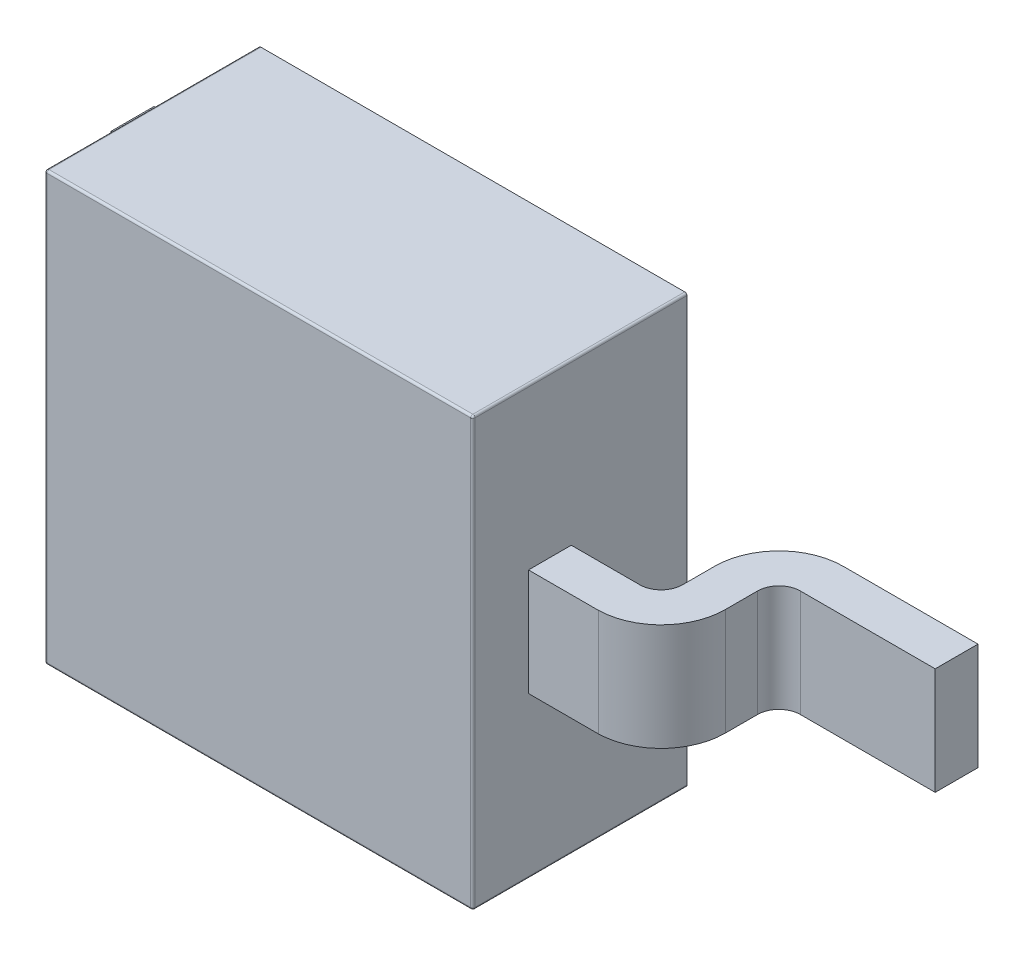
from build123d import *

# Parameters (mm, degrees)
SKETCH1_W      = 2
SKETCH1_H      = 2
EXTRUDE1_DEPTH = 1
SKETCH2_W      = 2
SKETCH2_H      = 1
EXTRUDE2_DEPTH = 0.2
SKETCH3_W      = 1.35
SKETCH3_H      = 0.5
EXTRUDE3_DEPTH = 0.75
EXTRUDE4_DEPTH = 2.25
FILLET1_R      = 0.01


with BuildPart() as part:
    # Sketch1 → Extrude1 (new body)
    with BuildSketch(Plane.XY.offset(0.01)):
        Rectangle(SKETCH1_W, SKETCH1_H)
    extrude(amount=EXTRUDE1_DEPTH)

    # Sketch2 → Extrude2 (add)
    with BuildSketch(Plane.XY):
        with Locations((-0.5, 0)):
            Rectangle(SKETCH2_W, SKETCH2_H)
    extrude(amount=EXTRUDE2_DEPTH)

    # Sketch3 → Extrude3 (add)
    with BuildSketch(Plane.XY):
        with Locations((1.675, 0)):
            Rectangle(SKETCH3_W, SKETCH3_H)
    extrude(amount=EXTRUDE3_DEPTH)

    # Sketch4 → Extrude4 (cut, through all)
    with BuildSketch(Plane.XZ.offset(0.25)):
        with BuildLine():
            Line((2.35, 0.2), (2.35, 0.75))
            Line((2.35, 0.75), (1.32, 0.750107803))
            ThreePointArc((1.32, 0.750107803), (1.532132034, 0.662239837), (1.62, 0.450107803))
            Line((1.62, 0.450107803), (1.62, 0.3))
            ThreePointArc((1.62, 0.3), (1.649289322, 0.229289322), (1.72, 0.2))
            Line((1.72, 0.2), (2.35, 0.2))
        make_face()
        with BuildLine():
            Line((1.32, 0.550107803), (1, 0.550107803))
            Line((1, 0.550107803), (1, 0))
            Line((1, 0), (1.72, 0))
            ThreePointArc((1.72, 0), (1.507867966, 0.087867966), (1.42, 0.3))
            Line((1.42, 0.3), (1.42, 0.450107803))
            ThreePointArc((1.42, 0.450107803), (1.390710678, 0.520818481), (1.32, 0.550107803))
        make_face()
    extrude(amount=-EXTRUDE4_DEPTH, mode=Mode.SUBTRACT)

    # Fillet1
    fillet1_edges = [part.edges().sort_by_distance(p)[0] for p in [
        (1, 0, 1.01),
        (0, 1, 1.01),
        (-1, 0, 1.01),
        (0, -1, 1.01),
        (-1, 1, 0.51),
        (1, 1, 0.51),
        (1, -1, 0.51),
        (-1, -1, 0.51),
    ]]
    fillet(fillet1_edges, radius=FILLET1_R)


solid = part.part
